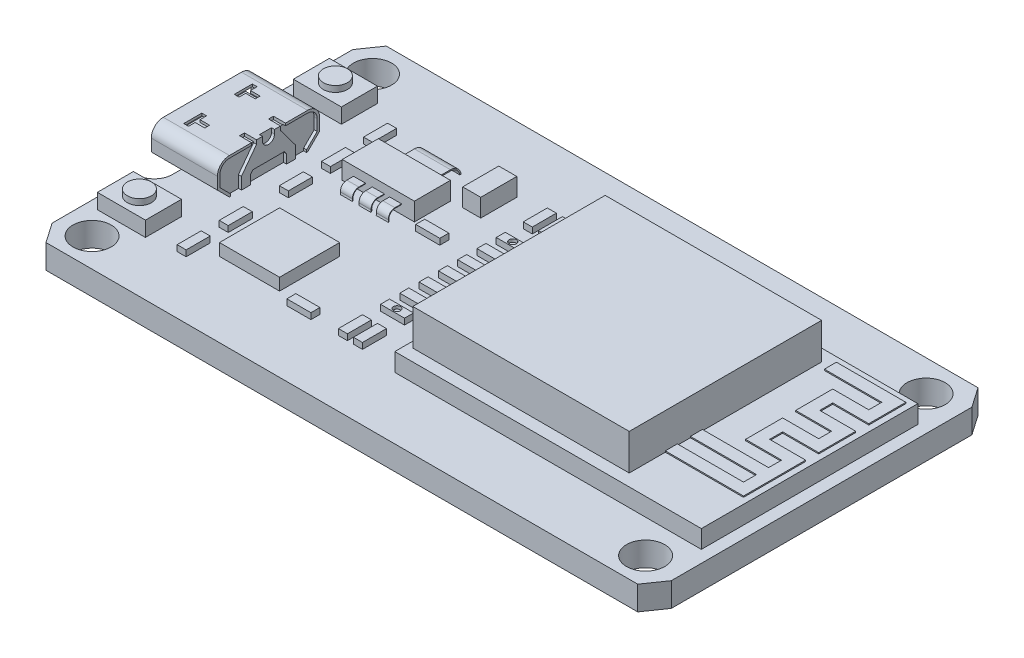
from build123d import *

# Parameters (mm, degrees)
CROQUIS1_W               = 51.5
CROQUIS1_H               = 28.3
SALIENTE_EXTRUIR1_DEPTH  = 2
CROQUIS2_R               = 1.5875
CORTAR_EXTRUIR1_DEPTH    = 2
CROQUIS13_OUTSIDE_W      = 65.26
CROQUIS13_OUTSIDE_H      = 42.06
CORTAR_EXTRUIR2_DEPTH    = 3
CROQUIS3_W               = 25.5
CROQUIS3_H               = 18
SALIENTE_EXTRUIR2_DEPTH  = 1.5
CROQUIS4_W               = 18
CROQUIS4_H               = 16
SALIENTE_EXTRUIR3_DEPTH  = 3
CROQUIS12_W              = 5.5
CROQUIS12_H              = 8.5
SALIENTE_EXTRUIR9_DEPTH  = 3
REDONDEO1_R              = 1
CORTAR_EXTRUIR3_DEPTH    = 6
CORTAR_EXTRUIR4_DEPTH    = 4
CORTAR_EXTRUIR5_DEPTH    = 0.25
CROQUIS17_W              = 1
CROQUIS17_H              = 0.411065286
CORTAR_EXTRUIR6_DEPTH    = 0.25
CROQUIS18_W              = 5.68961293
CROQUIS18_H              = 0.758953995
SALIENTE_EXTRUIR10_DEPTH = 3.25
CROQUIS19_W              = 4
CROQUIS19_H              = 3
SALIENTE_EXTRUIR11_DEPTH = 1.25
CROQUIS22_R              = 1
SALIENTE_EXTRUIR13_DEPTH = 0.5
CROQUIS23_W              = 0.75
CROQUIS23_H              = 2
CROQUIS23_W_2            = 2
CROQUIS23_H_2            = 0.75
SALIENTE_EXTRUIR14_DEPTH = 0.5
CROQUIS26_W              = 5
CROQUIS26_H              = 5
SALIENTE_EXTRUIR15_DEPTH = 1
CROQUIS27_W              = 1.5
CROQUIS27_H              = 3
SALIENTE_EXTRUIR16_DEPTH = 1.5
CROQUIS28_W              = 6
CROQUIS28_H              = 3
SALIENTE_EXTRUIR17_DEPTH = 1.5
SALIENTE_EXTRUIR18_DEPTH = 0.1
CROQUIS31_R              = 0.3
CORTAR_EXTRUIR7_DEPTH    = 0.25
CROQUIS33_W              = 3
CROQUIS33_H              = 0.1
CROQUIS35_W              = 1
CROQUIS35_H              = 0.05
CORTAR_EXTRUIR8_DEPTH    = 0.5


with BuildPart() as part:
    # Croquis1 → Saliente-Extruir1 (new body)
    with BuildSketch(Plane(origin=(0, 0, 0), x_dir=(1, 0, 0), z_dir=(0, 1, 0))):
        Rectangle(CROQUIS1_W, CROQUIS1_H)
    extrude(amount=SALIENTE_EXTRUIR1_DEPTH)

    # Croquis2 → Cortar-Extruir1 (cut)
    with BuildSketch(Plane(origin=(0, 2, 0), x_dir=(1, 0, 0), z_dir=(0, 1, 0))):
        with Locations((-23.1625, 11.5625)):
            Circle(CROQUIS2_R)
        with Locations((22.875, 11.5625)):
            Circle(CROQUIS2_R)
        with Locations((-23.1625, -11.7625)):
            Circle(CROQUIS2_R)
        with Locations((22.875, -11.7625)):
            Circle(CROQUIS2_R)
    extrude(amount=-CORTAR_EXTRUIR1_DEPTH, mode=Mode.SUBTRACT)

    # Croquis13 outside → Cortar-Extruir2 (cut)
    with BuildSketch(Plane(origin=(0, 2, 0), x_dir=(1, 0, 0), z_dir=(0, 1, 0))):
        Rectangle(CROQUIS13_OUTSIDE_W, CROQUIS13_OUTSIDE_H)
        with BuildLine():
            Line((25.75, 12.5), (25.75, -12.5))
            Line((25.75, -12.5), (24.60625, -14.15))
            Line((24.60625, -14.15), (-24.60625, -14.15))
            Line((-24.60625, -14.15), (-25.75, -12.5))
            Line((-25.75, -12.5), (-25.75, -5.5))
            ThreePointArc((-25.75, -5.5), (-24.689339828, -5.060660172), (-24.25, -4))
            Line((-24.25, -4), (-24.25, 4))
            ThreePointArc((-24.25, 4), (-24.689339828, 5.060660172), (-25.75, 5.5))
            Line((-25.75, 5.5), (-25.75, 12.5))
            Line((-25.75, 12.5), (-24.60625, 14.15))
            Line((-24.60625, 14.15), (24.60625, 14.15))
            Line((24.60625, 14.15), (25.75, 12.5))
        make_face(mode=Mode.SUBTRACT)
    extrude(amount=-CORTAR_EXTRUIR2_DEPTH, mode=Mode.SUBTRACT)

    # Croquis3 → Saliente-Extruir2 (add)
    with BuildSketch(Plane(origin=(0, 2, 0), x_dir=(1, 0, 0), z_dir=(0, 1, 0))):
        with Locations((12, 0)):
            Rectangle(CROQUIS3_W, CROQUIS3_H)
    extrude(amount=SALIENTE_EXTRUIR2_DEPTH)

    # Croquis4 → Saliente-Extruir3 (add)
    with BuildSketch(Plane(origin=(0, 3.5, 0), x_dir=(1, 0, 0), z_dir=(0, 1, 0))):
        with Locations((8.75, 0)):
            Rectangle(CROQUIS4_W, CROQUIS4_H)
    extrude(amount=SALIENTE_EXTRUIR3_DEPTH)

    # Croquis12 → Saliente-Extruir9 (add)
    with BuildSketch(Plane(origin=(0, 2, 0), x_dir=(1, 0, 0), z_dir=(0, 1, 0))):
        with Locations((-23, 0)):
            Rectangle(CROQUIS12_W, CROQUIS12_H)
    extrude(amount=SALIENTE_EXTRUIR9_DEPTH)

    # Redondeo1
    redondeo1_edges = [part.edges().sort_by_distance(p)[0] for p in [
        (-23, 5, 4.25),
        (-23, 5, -4.25),
    ]]
    fillet(redondeo1_edges, radius=REDONDEO1_R)

    # Croquis14 → Cortar-Extruir3 (cut)
    with BuildSketch(Plane.ZY.offset(25.75)):
        Polygon((-4.25, 2), (-3.25, 2), (-4.25, 3), align=None)
        Polygon((4.25, 3), (3.25, 2), (4.25, 2), align=None)
    extrude(amount=-CORTAR_EXTRUIR3_DEPTH, mode=Mode.SUBTRACT)

    # Croquis15 → Cortar-Extruir4 (cut)
    with BuildSketch(Plane.ZY.offset(25.75)):
        with BuildLine():
            Line((3.25, 4.8), (-3.25, 4.8))
            ThreePointArc((-3.25, 4.8), (-3.815685425, 4.565685425), (-4.05, 4))
            Line((-4.05, 4), (-4.05, 3.082842712))
            Line((-4.05, 3.082842712), (-3.167157288, 2.2))
            Line((-3.167157288, 2.2), (3.167157288, 2.2))
            Line((3.167157288, 2.2), (4.05, 3.082842712))
            Line((4.05, 3.082842712), (4.05, 4))
            ThreePointArc((4.05, 4), (3.815685425, 4.565685425), (3.25, 4.8))
        make_face()
    extrude(amount=-CORTAR_EXTRUIR4_DEPTH, mode=Mode.SUBTRACT)

    # Croquis16 → Cortar-Extruir5 (cut)
    with BuildSketch(Plane(origin=(-20.25, 0, 0), x_dir=(0, 0, -1), z_dir=(1, 0, 0))):
        Polygon((-1.5, 2.750073012), (-1.5, 2), (1.5, 2), (1.5, 2.750073012), (1.316867325, 2.994339073), (-1.316867325, 2.994339073), align=None)
        with BuildLine():
            Line((-2.25, 3), (-1, 4.667275256))
            Line((-1, 4.667275256), (-1, 5))
            Line((-1, 5), (-1.411065286, 5))
            Line((-1.411065286, 5), (-1.411065286, 4.8))
            Line((-1.411065286, 4.8), (-3.25, 4.8))
            ThreePointArc((-3.25, 4.8), (-3.815685425, 4.565685425), (-4.05, 4))
            Line((-4.05, 4), (-4.05, 3.082842712))
            Line((-4.05, 3.082842712), (-3.167157288, 2.2))
            Line((-3.167157288, 2.2), (-3.167157288, 2))
            Line((-3.167157288, 2), (-2.25, 2))
            Line((-2.25, 2), (-2.25, 3))
        make_face()
        with BuildLine():
            Line((-0.5, 5), (0.5, 5))
            Line((0.5, 5), (0.5, 4.667275256))
            ThreePointArc((0.5, 4.667275256), (0, 4.167275256), (-0.5, 4.667275256))
            Line((-0.5, 4.667275256), (-0.5, 5))
        make_face()
        with BuildLine():
            Line((3.167157288, 2.2), (3.167157288, 2))
            Line((3.167157288, 2), (2.25, 2))
            Line((2.25, 2), (2.25, 3))
            Line((2.25, 3), (1, 4.667275256))
            Line((1, 4.667275256), (1, 5))
            Line((1, 5), (1.411065286, 5))
            Line((1.411065286, 5), (1.411065286, 4.8))
            Line((1.411065286, 4.8), (3.25, 4.8))
            ThreePointArc((3.25, 4.8), (3.815685425, 4.565685425), (4.05, 4))
            Line((4.05, 4), (4.05, 3.082842712))
            Line((4.05, 3.082842712), (3.167157288, 2.2))
        make_face()
    extrude(amount=-CORTAR_EXTRUIR5_DEPTH, mode=Mode.SUBTRACT)

    # Croquis17 → Cortar-Extruir6 (cut)
    with BuildSketch(Plane(origin=(0, 5, 0), x_dir=(1, 0, 0), z_dir=(0, 1, 0))):
        with Locations((-20.75, -1.205532643)):
            Rectangle(CROQUIS17_W, CROQUIS17_H)
        with Locations((-20.75, 1.205532643)):
            Rectangle(CROQUIS17_W, CROQUIS17_H)
    extrude(amount=-CORTAR_EXTRUIR6_DEPTH, mode=Mode.SUBTRACT)

    # Croquis18 → Saliente-Extruir10 (add)
    with BuildSketch(Plane.ZY.offset(21.75)):
        with Locations((0, 3.814056829)):
            Rectangle(CROQUIS18_W, CROQUIS18_H)
    extrude(amount=SALIENTE_EXTRUIR10_DEPTH)

    # Croquis19 → Saliente-Extruir11 (add)
    with BuildSketch(Plane(origin=(0, 2, 0), x_dir=(1, 0, 0), z_dir=(0, 1, 0))):
        with Locations((-22.837294818, -8.15)):
            Rectangle(CROQUIS19_W, CROQUIS19_H)
        with Locations((-22.837294818, 8.15)):
            Rectangle(CROQUIS19_W, CROQUIS19_H)
    extrude(amount=SALIENTE_EXTRUIR11_DEPTH)

    # Croquis22 → Saliente-Extruir13 (add)
    with BuildSketch(Plane(origin=(0, 3.25, 0), x_dir=(1, 0, 0), z_dir=(0, 1, 0))):
        with Locations((-22.837294818, 8.15)):
            Circle(CROQUIS22_R)
        with Locations((-22.837294818, -8.15)):
            Circle(CROQUIS22_R)
    extrude(amount=SALIENTE_EXTRUIR13_DEPTH)

    # Croquis23 → Saliente-Extruir14 (add)
    with BuildSketch(Plane(origin=(0, 2, 0), x_dir=(1, 0, 0), z_dir=(0, 1, 0))):
        with Locations((-18.125, 3.65)):
            Rectangle(CROQUIS23_W, CROQUIS23_H)
        with Locations((-18.125, 7.15)):
            Rectangle(CROQUIS23_W, CROQUIS23_H)
        with Locations((-18.125, 0.15)):
            Rectangle(CROQUIS23_W, CROQUIS23_H)
        with Locations((-18.125, -8.35)):
            Rectangle(CROQUIS23_W, CROQUIS23_H)
        with Locations((-18.125, -4.85)):
            Rectangle(CROQUIS23_W, CROQUIS23_H)
        with Locations((-4.75, 3.208333333)):
            Rectangle(CROQUIS23_W_2, CROQUIS23_H_2)
        with Locations((-4.75, 4.8125)):
            Rectangle(CROQUIS23_W_2, CROQUIS23_H_2)
        with Locations((-4.75, 1.604166667)):
            Rectangle(CROQUIS23_W_2, CROQUIS23_H_2)
        with Locations((-4.75, 0)):
            Rectangle(CROQUIS23_W_2, CROQUIS23_H_2)
        with Locations((-4.75, -1.604166667)):
            Rectangle(CROQUIS23_W_2, CROQUIS23_H_2)
        with Locations((-4.75, -3.208333333)):
            Rectangle(CROQUIS23_W_2, CROQUIS23_H_2)
        with Locations((-4.75, -4.8125)):
            Rectangle(CROQUIS23_W_2, CROQUIS23_H_2)
        with Locations((-4.125, -7.6875)):
            Rectangle(CROQUIS23_W, CROQUIS23_H)
        with Locations((-5.375, -7.6875)):
            Rectangle(CROQUIS23_W, CROQUIS23_H)
        with Locations((-4.125, 7.6875)):
            Rectangle(CROQUIS23_W, CROQUIS23_H)
        with Locations((-5.375, 7.6875)):
            Rectangle(CROQUIS23_W, CROQUIS23_H)
        with Locations((-9.0373377, -8.3125)):
            Rectangle(CROQUIS23_W_2, CROQUIS23_H_2)
        with Locations((-9.0373377, 2.40625)):
            Rectangle(CROQUIS23_W_2, CROQUIS23_H_2)
    extrude(amount=SALIENTE_EXTRUIR14_DEPTH)

    # Croquis26 → Saliente-Extruir15 (add)
    with BuildSketch(Plane(origin=(0, 2, 0), x_dir=(1, 0, 0), z_dir=(0, 1, 0))):
        with Locations((-13.89366885, -5.4375)):
            Rectangle(CROQUIS26_W, CROQUIS26_H)
    extrude(amount=SALIENTE_EXTRUIR15_DEPTH)

    # Croquis27 → Saliente-Extruir16 (add)
    with BuildSketch(Plane(origin=(0, 2, 0), x_dir=(1, 0, 0), z_dir=(0, 1, 0))):
        with Locations((-9.0373377, 7.1875)):
            Rectangle(CROQUIS27_W, CROQUIS27_H)
    extrude(amount=SALIENTE_EXTRUIR16_DEPTH)

    # Croquis28 → Saliente-Extruir17 (add)
    with BuildSketch(Plane(origin=(0, 2, 0), x_dir=(1, 0, 0), z_dir=(0, 1, 0))):
        with Locations((-13.76866885, 4.15)):
            Rectangle(CROQUIS28_W, CROQUIS28_H)
    extrude(amount=SALIENTE_EXTRUIR17_DEPTH)

    # Croquis30 → Saliente-Extruir18 (add)
    with BuildSketch(Plane(origin=(0, 3.5, 0), x_dir=(1, 0, 0), z_dir=(0, 1, 0))):
        Polygon((18.479746063, 7.5), (23.254418174, 7.5), (23.254418174, 6.416666667), (20.258739977, 6.416666667), (20.258739977, 3.333333333), (23.254418174, 3.333333333), (23.254418174, 2.25), (20.258739977, 2.25), (20.258739977, -0.833333333), (23.254418174, -0.833333333), (23.254418174, -1.916666667), (17.75, -1.916666667), (17.75, -2.916666667), (23.254418174, -2.916666667), (23.254418174, -4), (17.75, -4), (17.75, -5), (24.254418174, -5), (24.254418174, -2.416666667), (24.254418174, 0.166666667), (21.258739977, 0.166666667), (21.258739977, 1.25), (24.254418174, 1.25), (24.254418174, 4.333333333), (21.258739977, 4.333333333), (21.258739977, 5.416666667), (24.254418174, 5.416666667), (24.254418174, 8.5), (18.479746063, 8.5), align=None)
    extrude(amount=SALIENTE_EXTRUIR18_DEPTH)

    # Croquis31 → Cortar-Extruir7 (cut)
    with BuildSketch(Plane(origin=(0, 2.5, 0), x_dir=(1, 0, 0), z_dir=(0, 1, 0))):
        with Locations((-4.75, 4.8125)):
            Circle(CROQUIS31_R)
        with Locations((-4.75, -4.8125)):
            Circle(CROQUIS31_R)
    extrude(amount=-CORTAR_EXTRUIR7_DEPTH, mode=Mode.SUBTRACT)

    # Barrer1: sweep along a path in Croquis32
    with BuildLine(Plane.ZY.offset(13.76866885)) as barrer1_path:
        Line((-5.65, 2.75), (-7.153654608, 2.75))
        ThreePointArc((-7.153654608, 2.75), (-7.770370245, 2.494548019), (-8.025822226, 1.877832382))
    # Croquis33 → Barrer1 (sweep)
    with BuildSketch(Plane(origin=(0, 0, -5.65), x_dir=(-1, 0, 0), z_dir=(0, 0, -1))):
        with Locations((13.76866885, 2.714914663)):
            Rectangle(CROQUIS33_W, CROQUIS33_H)
    sweep(path=barrer1_path.line)

    # Barrer2: sweep along a path in Croquis34
    with BuildLine(Plane.ZY.offset(13.76866885)) as barrer2_path:
        Line((-2.65, 2.75), (-2.095942459, 2.75))
        ThreePointArc((-2.095942459, 2.75), (-1.707871888, 2.575411266), (-1.581097256, 2.16919927))
        ThreePointArc((-1.581097256, 2.16919927), (-1.436021267, 1.850627734), (-1.086379703, 1.833726789))
    # Croquis35 → Barrer2 (sweep)
    with BuildSketch(Plane.XY.offset(-2.65)):
        with Locations((-13.76866885, 2.748535406)):
            Rectangle(CROQUIS35_W, CROQUIS35_H)
        with Locations((-15.33116885, 2.736035406)):
            Rectangle(CROQUIS35_W, CROQUIS35_H)
        with Locations((-12.33116885, 2.748535406)):
            Rectangle(CROQUIS35_W, CROQUIS35_H)
    sweep(path=barrer2_path.line)

    # Croquis36 → Cortar-Extruir8 (cut)
    with BuildSketch(Plane(origin=(0, 5, 0), x_dir=(1, 0, 0), z_dir=(0, 1, 0))):
        Polygon((-24.05, -2.3), (-23.25, -2.3), (-23.25, -1.9), (-24.05, -1.9), (-24.05, -1.35), (-24.45, -1.35), (-24.45, -2.85), (-24.05, -2.85), align=None)
        Polygon((-24.05, 1.35), (-24.05, 1.9), (-23.25, 1.9), (-23.25, 2.3), (-24.05, 2.3), (-24.05, 2.85), (-24.45, 2.85), (-24.45, 1.35), align=None)
    extrude(amount=-CORTAR_EXTRUIR8_DEPTH, mode=Mode.SUBTRACT)


solid = part.part
